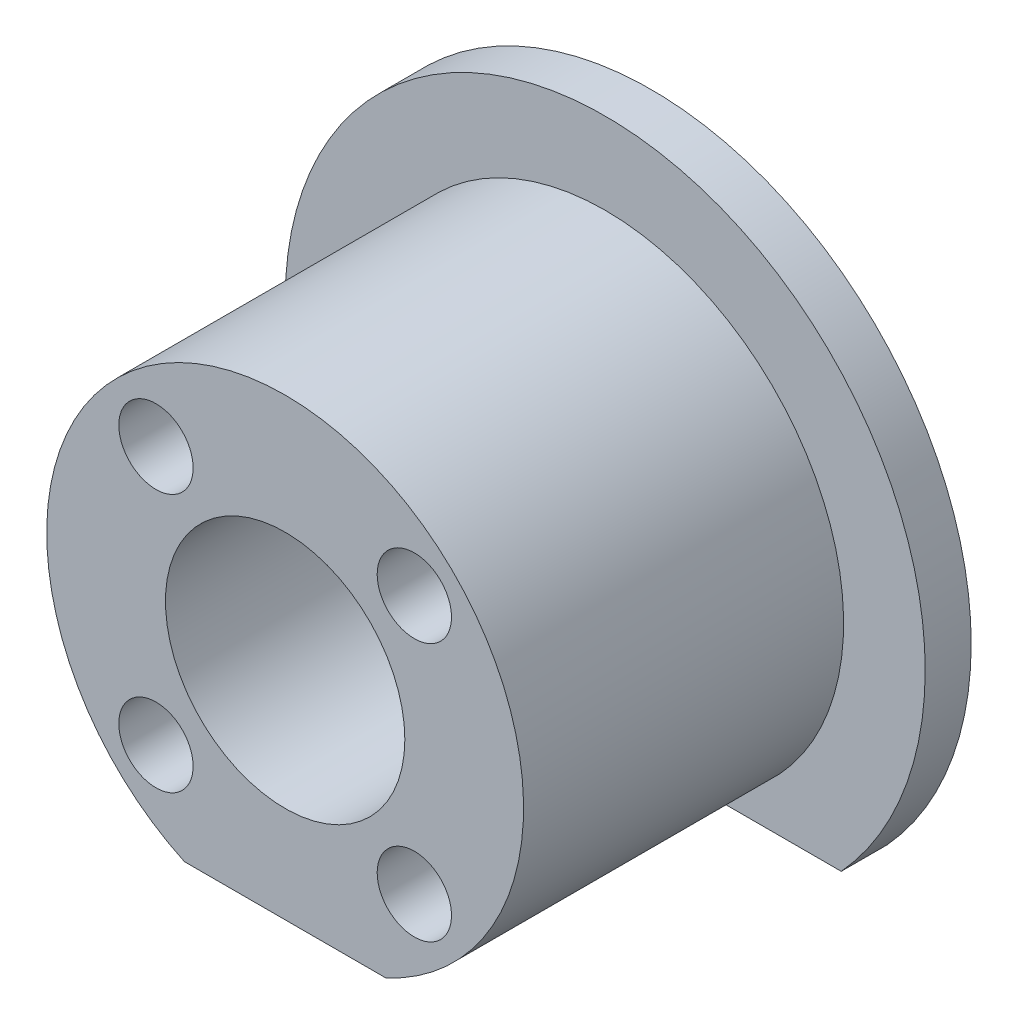
from build123d import *

# Parameters (mm, degrees)
SKETCH1_R           = 4.750000025
BOSS_EXTRUDE1_DEPTH = 14.524999906
SKETCH3_R           = 1.474999971
CUT_EXTRUDE1_DEPTH  = 19.05
BOSS_EXTRUDE2_DEPTH = 1.825


with BuildPart() as part:
    # Sketch1 → Boss-Extrude1 (new body)
    with BuildSketch(Plane.XY):
        with BuildLine():
            Line((-3.998602683, -8.575031127), (3.998602683, -8.575031127))
            ThreePointArc((3.998602683, -8.575031127), (0, 9.4615), (-3.998602683, -8.575031127))
        make_face()
        Circle(SKETCH1_R, mode=Mode.SUBTRACT)
    extrude(amount=BOSS_EXTRUDE1_DEPTH)

    # Sketch3 → Cut-Extrude1 (cut)
    with BuildSketch(Plane(origin=(0, 0, 0), x_dir=(-1, 0, 0), z_dir=(0, 0, -1))):
        with Locations((5.126524148, -5.126524148)):
            Circle(SKETCH3_R)
        with Locations((-5.126524148, -5.126524148)):
            Circle(SKETCH3_R)
        with Locations((-5.126524148, 5.126524148)):
            Circle(SKETCH3_R)
        with Locations((5.126524148, 5.126524148)):
            Circle(SKETCH3_R)
    extrude(amount=-CUT_EXTRUDE1_DEPTH, mode=Mode.SUBTRACT)

    # Sketch4 → Boss-Extrude2 (add)
    with BuildSketch(Plane.XY):
        with BuildLine():
            Line((-3.998602683, -8.575031127), (-9.367968892, -8.575031127))
            ThreePointArc((-9.367968892, -8.575031127), (0, 12.7), (9.367968892, -8.575031127))
            Line((9.367968892, -8.575031127), (3.998602683, -8.575031127))
            ThreePointArc((3.998602683, -8.575031127), (0, 9.4615), (-3.998602683, -8.575031127))
        make_face()
    extrude(amount=BOSS_EXTRUDE2_DEPTH)


solid = part.part
